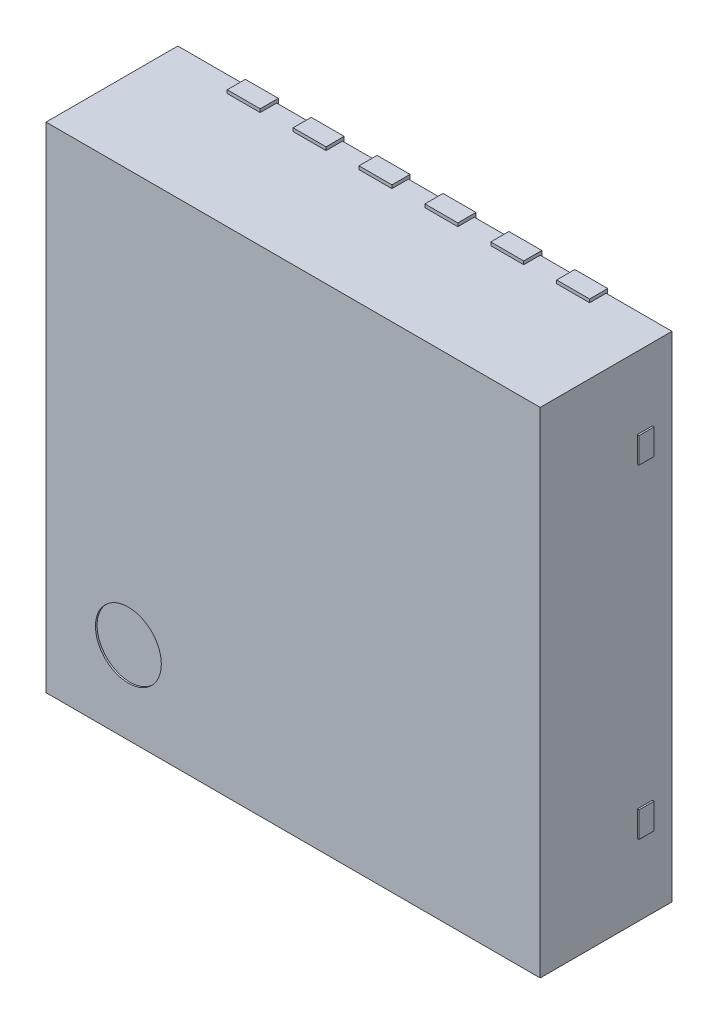
from build123d import *

# Parameters (mm, degrees)
SKETCH1_W              = 3
SKETCH1_H              = 3
BOSS_EXTRUDE1_DEPTH    = 0.8
SKETCH2_W              = 0.2
SKETCH2_H              = 0.42
BOSS_EXTRUDE2_DEPTH    = 0.11
BOSS_EXTRUDE2_2_DEPTH  = 0.11
BOSS_EXTRUDE2_3_DEPTH  = 0.11
BOSS_EXTRUDE2_4_DEPTH  = 0.11
BOSS_EXTRUDE2_5_DEPTH  = 0.11
BOSS_EXTRUDE2_6_DEPTH  = 0.11
BOSS_EXTRUDE2_7_DEPTH  = 0.11
BOSS_EXTRUDE2_8_DEPTH  = 0.11
BOSS_EXTRUDE2_9_DEPTH  = 0.11
BOSS_EXTRUDE2_10_DEPTH = 0.11
BOSS_EXTRUDE2_11_DEPTH = 0.11
BOSS_EXTRUDE2_12_DEPTH = 0.11
BOSS_EXTRUDE2_13_DEPTH = 0.11
SKETCH3_W              = 0.092125769
SKETCH3_H              = 0.15597197
BOSS_EXTRUDE3_DEPTH    = 0.01
BOSS_EXTRUDE3_2_DEPTH  = 0.01
SKETCH4_R              = 0.2
CUT_EXTRUDE1_DEPTH     = 0.01


with BuildPart() as part:
    # Sketch1 → Boss-Extrude1 (new body)
    with BuildSketch(Plane.XY.offset(0.01)):
        Rectangle(SKETCH1_W, SKETCH1_H)
    extrude(amount=BOSS_EXTRUDE1_DEPTH)


with BuildPart() as body_2:
    # Sketch2 → Boss-Extrude2 (new body)
    with BuildSketch(Plane.XY):
        with Locations((-1, -1.31)):
            Rectangle(SKETCH2_W, SKETCH2_H)
    extrude(amount=BOSS_EXTRUDE2_DEPTH)


with BuildPart() as body_3:
    # Sketch2 → Boss-Extrude2 2 (new body)
    with BuildSketch(Plane.XY):
        with Locations((-0.6, -1.31)):
            Rectangle(SKETCH2_W, SKETCH2_H)
    extrude(amount=BOSS_EXTRUDE2_2_DEPTH)


with BuildPart() as body_4:
    # Sketch2 → Boss-Extrude2 3 (new body)
    with BuildSketch(Plane.XY):
        with Locations((-0.2, -1.31)):
            Rectangle(SKETCH2_W, SKETCH2_H)
    extrude(amount=BOSS_EXTRUDE2_3_DEPTH)


with BuildPart() as body_5:
    # Sketch2 → Boss-Extrude2 4 (new body)
    with BuildSketch(Plane.XY):
        with Locations((0.2, -1.31)):
            Rectangle(SKETCH2_W, SKETCH2_H)
    extrude(amount=BOSS_EXTRUDE2_4_DEPTH)


with BuildPart() as body_6:
    # Sketch2 → Boss-Extrude2 5 (new body)
    with BuildSketch(Plane.XY):
        with Locations((0.6, -1.31)):
            Rectangle(SKETCH2_W, SKETCH2_H)
    extrude(amount=BOSS_EXTRUDE2_5_DEPTH)


with BuildPart() as body_7:
    # Sketch2 → Boss-Extrude2 6 (new body)
    with BuildSketch(Plane.XY):
        with Locations((1, -1.31)):
            Rectangle(SKETCH2_W, SKETCH2_H)
    extrude(amount=BOSS_EXTRUDE2_6_DEPTH)


with BuildPart() as body_8:
    # Sketch2 → Boss-Extrude2 7 (new body)
    with BuildSketch(Plane.XY):
        with Locations((1, 1.31)):
            Rectangle(SKETCH2_W, SKETCH2_H)
    extrude(amount=BOSS_EXTRUDE2_7_DEPTH)


with BuildPart() as body_9:
    # Sketch2 → Boss-Extrude2 8 (new body)
    with BuildSketch(Plane.XY):
        with Locations((0.6, 1.31)):
            Rectangle(SKETCH2_W, SKETCH2_H)
    extrude(amount=BOSS_EXTRUDE2_8_DEPTH)


with BuildPart() as body_10:
    # Sketch2 → Boss-Extrude2 9 (new body)
    with BuildSketch(Plane.XY):
        with Locations((0.2, 1.31)):
            Rectangle(SKETCH2_W, SKETCH2_H)
    extrude(amount=BOSS_EXTRUDE2_9_DEPTH)


with BuildPart() as body_11:
    # Sketch2 → Boss-Extrude2 10 (new body)
    with BuildSketch(Plane.XY):
        with Locations((-0.2, 1.31)):
            Rectangle(SKETCH2_W, SKETCH2_H)
    extrude(amount=BOSS_EXTRUDE2_10_DEPTH)


with BuildPart() as body_12:
    # Sketch2 → Boss-Extrude2 11 (new body)
    with BuildSketch(Plane.XY):
        with Locations((-0.6, 1.31)):
            Rectangle(SKETCH2_W, SKETCH2_H)
    extrude(amount=BOSS_EXTRUDE2_11_DEPTH)


with BuildPart() as body_13:
    # Sketch2 → Boss-Extrude2 12 (new body)
    with BuildSketch(Plane.XY):
        with Locations((-1, 1.31)):
            Rectangle(SKETCH2_W, SKETCH2_H)
    extrude(amount=BOSS_EXTRUDE2_12_DEPTH)


with BuildPart() as body_14:
    # Sketch2 → Boss-Extrude2 13 (new body)
    with BuildSketch(Plane.XY):
        Polygon((-1.1, -0.59), (-0.85, -0.84), (1.1, -0.84), (1.1, 0.84), (-1.1, 0.84), align=None)
    extrude(amount=BOSS_EXTRUDE2_13_DEPTH)


with BuildPart() as body_15:
    # Sketch3 → Boss-Extrude3 (new body)
    with BuildSketch(Plane(origin=(1.5, 0, 0), x_dir=(0, 0, -1), z_dir=(1, 0, 0))):
        with Locations((-0.173937116, 0.983999633)):
            Rectangle(SKETCH3_W, SKETCH3_H)
    boss_extrude3 = extrude(amount=BOSS_EXTRUDE3_DEPTH)


with BuildPart() as body_16:
    # Sketch3 → Boss-Extrude3 2 (new body)
    with BuildSketch(Plane(origin=(1.5, 0, 0), x_dir=(0, 0, -1), z_dir=(1, 0, 0))):
        with Locations((-0.173937116, -0.983999633)):
            Rectangle(SKETCH3_W, SKETCH3_H)
    boss_extrude3_2 = extrude(amount=BOSS_EXTRUDE3_2_DEPTH)


with BuildPart() as part_1:
    add(part.part)

    # Mirror1: Boss-Extrude3, Boss-Extrude3 2 across plane
    add(boss_extrude3.mirror(Plane(origin=(0, 0, 0), x_dir=(0, 0, 1), z_dir=(1, 0, 0))))
    add(boss_extrude3_2.mirror(Plane(origin=(0, 0, 0), x_dir=(0, 0, 1), z_dir=(1, 0, 0))))

    # Sketch4 → Cut-Extrude1 (cut)
    with BuildSketch(Plane.XY.offset(0.81)):
        with Locations((-1, -1)):
            Circle(SKETCH4_R)
    extrude(amount=-CUT_EXTRUDE1_DEPTH, mode=Mode.SUBTRACT)


solid = Compound([body_2.part, body_3.part, body_4.part, body_5.part, body_6.part, body_7.part, body_8.part, body_9.part, body_10.part, body_11.part, body_12.part, body_13.part, body_14.part, body_15.part, body_16.part, part_1.part])
